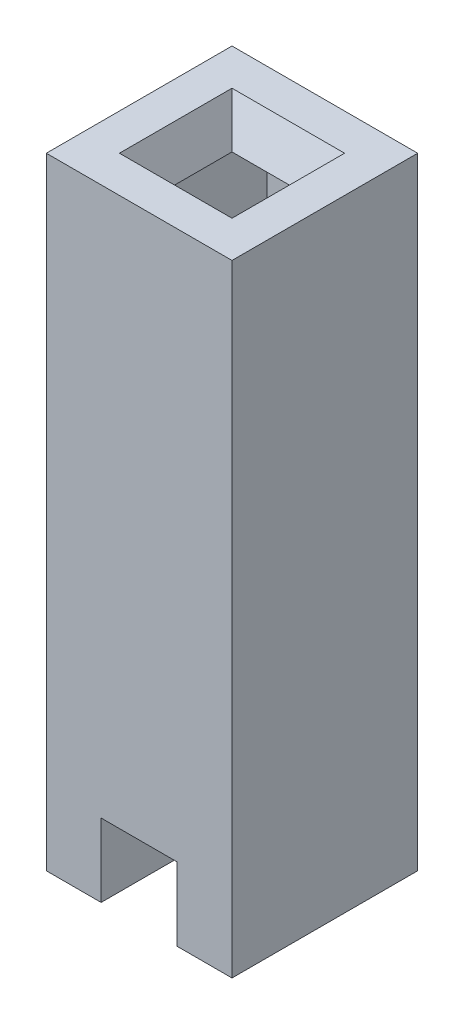
from build123d import *

# Parameters (mm, degrees)
BOSS_EXTRUDE1_DEPTH = 2.54
SKETCH2_W           = 1.04
SKETCH2_H           = 2
CUT_EXTRUDE1_DEPTH  = 7
SKETCH3_W           = 1.54
SKETCH3_H           = 1.54
CUT_EXTRUDE2_DEPTH  = 0.5
CUT_EXTRUDE2_TAPER  = 27


with BuildPart() as part:
    # Sketch1 → Boss-Extrude1 (new body)
    with BuildSketch(Plane.XY):
        Polygon((-1.79, 0), (-2.54, 0), (-2.54, 8.5), (0, 8.5), (0, 0), (-0.75, 0), (-0.75, 1), (-1.79, 1), align=None)
    extrude(amount=BOSS_EXTRUDE1_DEPTH)

    # Sketch2 → Cut-Extrude1 (cut)
    with BuildSketch(Plane.XZ.offset(-1)):
        with Locations((-1.27, 1.27)):
            Rectangle(SKETCH2_W, SKETCH2_H)
    extrude(amount=-CUT_EXTRUDE1_DEPTH, mode=Mode.SUBTRACT)

    # Sketch3 → Cut-Extrude2 (cut)
    with BuildSketch(Plane(origin=(0, 8.5, 0), x_dir=(1, 0, 0), z_dir=(0, 1, 0))):
        with Locations((-1.27, -1.27)):
            Rectangle(SKETCH3_W, SKETCH3_H)
    extrude(amount=-CUT_EXTRUDE2_DEPTH, taper=CUT_EXTRUDE2_TAPER, mode=Mode.SUBTRACT)


solid = part.part
